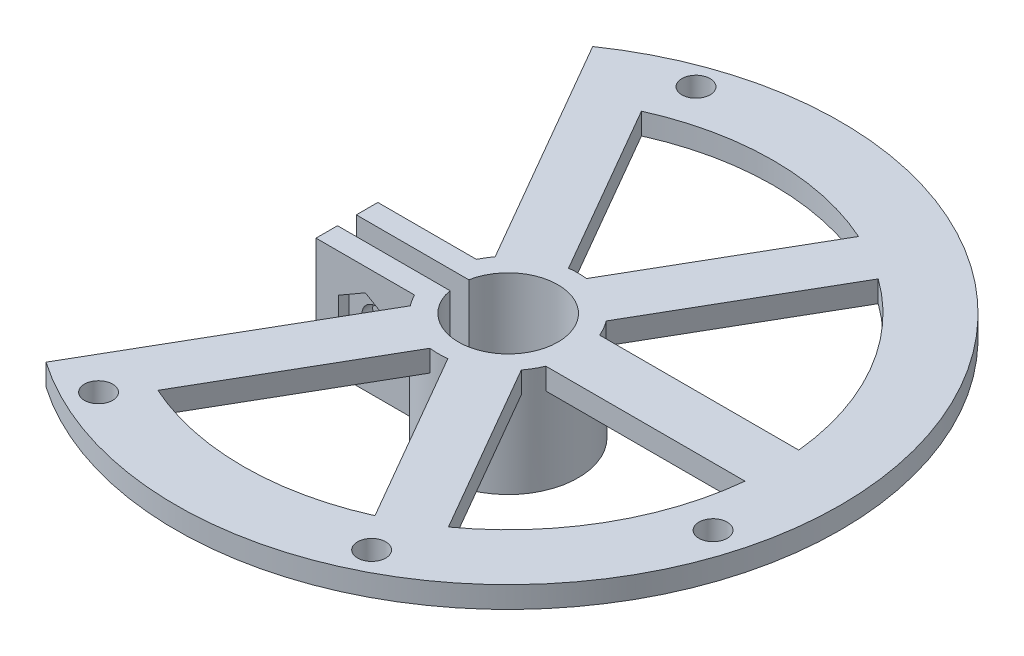
from build123d import *

# Parameters (mm, degrees)
BOSS_EXTRUDE2_START     = 10
BOSS_EXTRUDE2_DEPTH     = 8
CUT_EXTRUDE1_DEPTH      = 23.896506284
CUT_EXTRUDE1_DEPTH_BACK = 23.896506284
SKETCH6_R               = 1.05
CUT_EXTRUDE2_DEPTH      = 0.8
BOSS_EXTRUDE6_START     = 1.6
BOSS_EXTRUDE6_DEPTH     = 1.6
SKETCH9_R               = 1.05
CUT_EXTRUDE3_DEPTH      = 36.860892421


with BuildPart() as part:
    # Sketch2 → Boss-Extrude2 (new body)
    with BuildSketch(Plane(origin=(0, 0, 0), x_dir=(1, 0, 0), z_dir=(0, 1, 0)).offset(BOSS_EXTRUDE2_START)):
        with BuildLine():
            Line((-4.663689527, 2.3), (-12, 2.3))
            Line((-12, 2.3), (-12, 0.7))
            Line((-12, 0.7), (-3.633180425, 0.7))
            ThreePointArc((-3.633180425, 0.7), (3.7, 0), (-3.633180425, -0.7))
            Line((-3.633180425, -0.7), (-12, -0.7))
            Line((-12, -0.7), (-12, -2.3))
            Line((-12, -2.3), (-4.663689527, -2.3))
            ThreePointArc((-4.663689527, -2.3), (5.2, 0), (-4.663689527, 2.3))
        make_face()
    extrude(amount=BOSS_EXTRUDE2_DEPTH)

    # Sketch6 → Cut-Extrude1 (cut, two sides: drawn at the far end of the back side and taken through both)
    with BuildSketch(Plane.XY.offset(2.3).offset(-CUT_EXTRUDE1_DEPTH_BACK)):
        with Locations((-8.331844763, 14)):
            Circle(SKETCH6_R)
    extrude(amount=CUT_EXTRUDE1_DEPTH + CUT_EXTRUDE1_DEPTH_BACK, mode=Mode.SUBTRACT)

    # Sketch7 → Cut-Extrude2 (cut)
    with BuildSketch(Plane.XY.offset(2.3)):
        Polygon((-6.331844763, 15.154700538), (-8.331844763, 16.309401077), (-10.331844763, 15.154700538), (-10.331844763, 12.845299462), (-8.331844763, 11.690598923), (-6.331844763, 12.845299462), align=None)
    extrude(amount=-CUT_EXTRUDE2_DEPTH, mode=Mode.SUBTRACT)

    # Sketch8 → Boss-Extrude6 (add)
    with BuildSketch(Plane.XZ.offset(-18).offset(BOSS_EXTRUDE6_START)):
        with BuildLine():
            Line((0.667949192, -5.156921938), (8.076329488, -17.988613012))
            ThreePointArc((8.076329488, -17.988613012), (0, -19.718450651), (-8.076329488, -17.988613012))
            Line((-8.076329488, -17.988613012), (-0.667949192, -5.156921938))
            ThreePointArc((-0.667949192, -5.156921938), (-2.6, -4.5033321), (-4.132050808, -3.156921938))
            Line((-4.132050808, -3.156921938), (-11.540431103, -15.988613012))
            Line((-11.540431103, -15.988613012), (-14.050754094, -20.336619975))
            ThreePointArc((-14.050754094, -20.336619975), (24.718450651, 0), (-14.050754094, 20.336619975))
            Line((-14.050754094, 20.336619975), (-11.540431103, 15.988613012))
            Line((-11.540431103, 15.988613012), (-4.132050808, 3.156921938))
            ThreePointArc((-4.132050808, 3.156921938), (-2.6, 4.5033321), (-0.667949192, 5.156921938))
            Line((-0.667949192, 5.156921938), (-8.076329488, 17.988613012))
            ThreePointArc((-8.076329488, 17.988613012), (0, 19.718450651), (8.076329488, 17.988613012))
            Line((8.076329488, 17.988613012), (0.667949192, 5.156921938))
            ThreePointArc((0.667949192, 5.156921938), (2.6, 4.5033321), (4.132050808, 3.156921938))
            Line((4.132050808, 3.156921938), (11.540431103, 15.988613012))
            ThreePointArc((11.540431103, 15.988613012), (17.076679187, 9.859225326), (19.616760591, 2))
            Line((19.616760591, 2), (4.8, 2))
            ThreePointArc((4.8, 2), (5.2, 0), (4.8, -2))
            Line((4.8, -2), (19.616760591, -2))
            ThreePointArc((19.616760591, -2), (17.076679187, -9.859225326), (11.540431103, -15.988613012))
            Line((11.540431103, -15.988613012), (4.132050808, -3.156921938))
            ThreePointArc((4.132050808, -3.156921938), (2.6, -4.5033321), (0.667949192, -5.156921938))
        make_face()
    extrude(amount=-BOSS_EXTRUDE6_DEPTH)

    # Sketch9 → Cut-Extrude3 (cut, through all)
    with BuildSketch(Plane(origin=(0, 18, 0), x_dir=(1, 0, 0), z_dir=(0, 1, 0))):
        with Locations((-7.62, 21.59)):
            Circle(SKETCH9_R)
        with Locations((-10.16, -20.32)):
            Circle(SKETCH9_R)
        with Locations((10.16, -20.32)):
            Circle(SKETCH9_R)
        with Locations((21.59, -6.35)):
            Circle(SKETCH9_R)
    extrude(amount=-CUT_EXTRUDE3_DEPTH, mode=Mode.SUBTRACT)


solid = part.part
